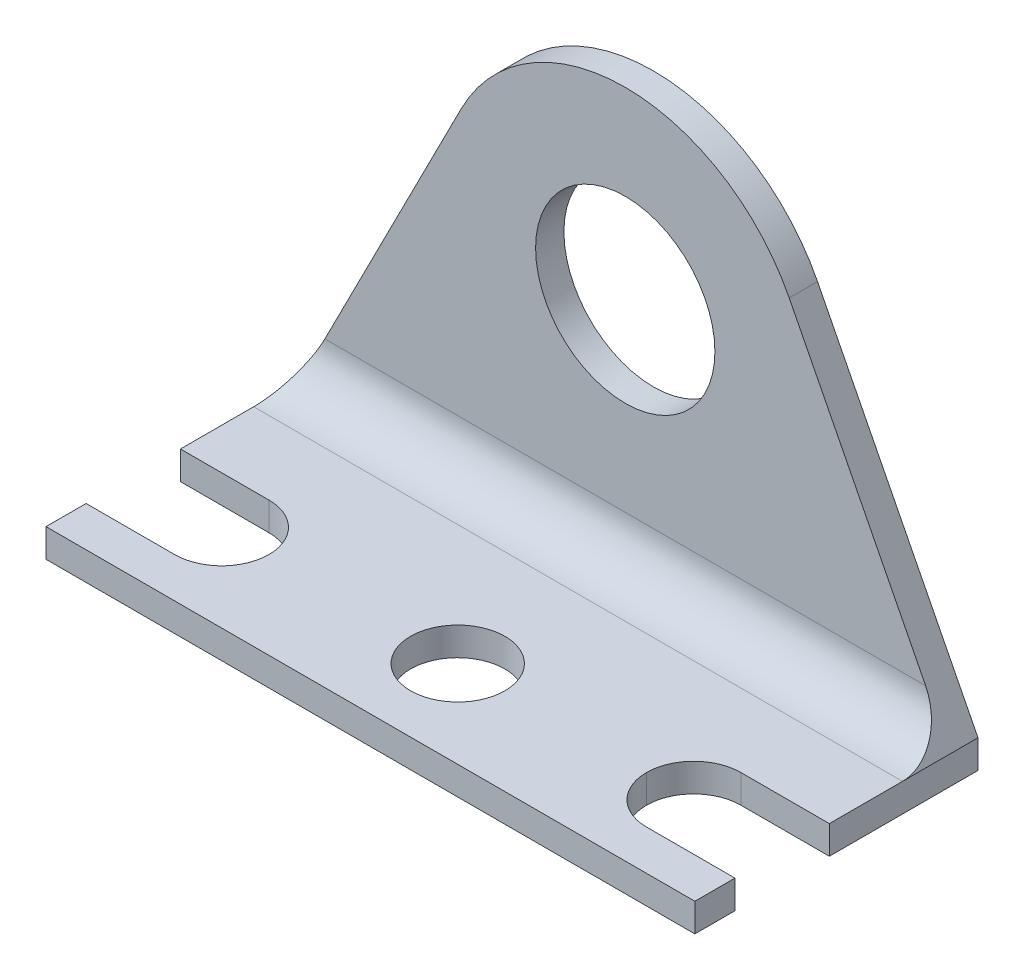
from build123d import *

# Parameters (mm, degrees)
SKETCH1_R               = 4.826
EXTRUDE1_DEPTH          = 1.524
SKETCH2_W               = 34.925
SKETCH2_H               = 1.524
EXTRUDE2_DEPTH          = 15.24
SKETCH3_R               = 2.54
CUT_EXTRUDE1_DEPTH      = 33.199509472
CUT_EXTRUDE2_DEPTH      = 33.199509472
CUT_EXTRUDE2_DEPTH_BACK = 33.199509472
FILLET1_R               = 2.54


with BuildPart() as part:
    # Sketch1 → Extrude1 (new body)
    with BuildSketch(Plane.XY):
        with BuildLine():
            Line((-17.4625, 0), (17.4625, 0))
            Line((17.4625, 0), (17.4625, 1.524))
            Line((17.4625, 1.524), (8.825639974, 18.468545882))
            ThreePointArc((8.825639974, 18.468545882), (5.175241081, 22.416639317), (0, 23.876))
            ThreePointArc((0, 23.876), (-5.175241081, 22.416639317), (-8.825639974, 18.468545882))
            Line((-8.825639974, 18.468545882), (-17.4625, 1.524))
            Line((-17.4625, 1.524), (-17.4625, 0))
        make_face()
        with Locations(Location((0, 13.97, 0), (0, 0, 180))):
            Circle(SKETCH1_R, mode=Mode.SUBTRACT)
    extrude(amount=EXTRUDE1_DEPTH)

    # Sketch2 → Extrude2 (add)
    with BuildSketch(Plane(origin=(0, 0, 0), x_dir=(-1, 0, 0), z_dir=(0, 0, -1))):
        with Locations((0, 0.762)):
            Rectangle(SKETCH2_W, SKETCH2_H)
    extrude(amount=-EXTRUDE2_DEPTH)

    # Sketch3 → Cut-Extrude1 (cut, through all)
    with BuildSketch(Plane(origin=(0, 1.524, 0), x_dir=(-1, 0, 0), z_dir=(0, 1, 0))):
        with Locations(Location((0, 10.541, 0), (0, 0, 90))):
            Circle(SKETCH3_R)
    extrude(amount=-CUT_EXTRUDE1_DEPTH, mode=Mode.SUBTRACT)

    # Sketch4 → Cut-Extrude2 (cut, two sides)
    with BuildSketch(Plane(origin=(0, 1.524, 0), x_dir=(-1, 0, 0), z_dir=(0, 1, 0))) as cut_extrude2_sk:
        with BuildLine():
            Line((12.7, 8.001), (17.4625, 8.001))
            Line((17.4625, 8.001), (17.4625, 13.081))
            Line((17.4625, 13.081), (12.7, 13.081))
            ThreePointArc((12.7, 13.081), (10.903948776, 12.337051224), (10.16, 10.541))
            ThreePointArc((10.16, 10.541), (10.903948776, 8.744948776), (12.7, 8.001))
        make_face()
    cut_extrude2 = extrude(amount=CUT_EXTRUDE2_DEPTH, mode=Mode.SUBTRACT)
    cut_extrude2 = cut_extrude2 + extrude(cut_extrude2_sk.sketch, amount=-CUT_EXTRUDE2_DEPTH_BACK, mode=Mode.SUBTRACT)

    # Mirror1: Cut-Extrude2 across plane
    add(cut_extrude2.mirror(Plane(origin=(0, 0, 0), x_dir=(0, 0, 1), z_dir=(1, 0, 0))), mode=Mode.SUBTRACT)

    # Fillet1
    fillet1_edges = [part.edges().sort_by_distance(p)[0] for p in [
        (0, 1.524, 1.524),
    ]]
    fillet(fillet1_edges, radius=FILLET1_R)


solid = part.part
